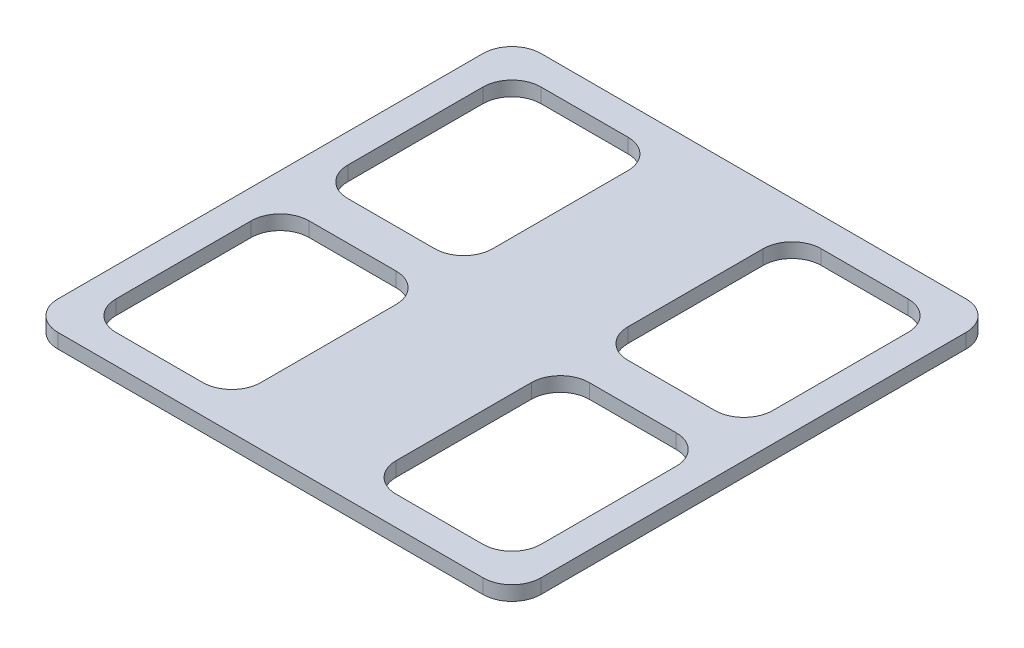
from build123d import *

# Parameters (mm, degrees)
EXTRUDE_1_DEPTH = 15


with BuildPart() as part:
    # 草图1 → 凸台-拉伸1 (new body)
    with BuildSketch(Plane(origin=(0, 0, 0), x_dir=(1, 0, 0), z_dir=(0, 1, 0))):
        with BuildLine():
            Line((220, 250), (-220, 250))
            ThreePointArc((-220, 250), (-241.213203436, 241.213203436), (-250, 220))
            Line((-250, 220), (-250, -220))
            ThreePointArc((-250, -220), (-241.213203436, -241.213203436), (-220, -250))
            Line((-220, -250), (220, -250))
            ThreePointArc((220, -250), (241.213203436, -241.213203436), (250, -220))
            Line((250, -220), (250, 220))
            ThreePointArc((250, 220), (241.213203436, 241.213203436), (220, 250))
        make_face()
        with BuildLine():
            Line((-100, 20), (-190, 20))
            ThreePointArc((-190, 20), (-211.213203436, 28.786796564), (-220, 50))
            Line((-220, 50), (-220, 190))
            ThreePointArc((-220, 190), (-211.213203436, 211.213203436), (-190, 220))
            Line((-190, 220), (-100, 220))
            ThreePointArc((-100, 220), (-78.786796564, 211.213203436), (-70, 190))
            Line((-70, 190), (-70, 50))
            ThreePointArc((-70, 50), (-78.786796564, 28.786796564), (-100, 20))
        make_face(mode=Mode.SUBTRACT)
        with BuildLine():
            Line((220, 50), (220, 190))
            ThreePointArc((220, 190), (211.213203436, 211.213203436), (190, 220))
            Line((190, 220), (100, 220))
            ThreePointArc((100, 220), (78.786796564, 211.213203436), (70, 190))
            Line((70, 190), (70, 50))
            ThreePointArc((70, 50), (78.786796564, 28.786796564), (100, 20))
            Line((100, 20), (190, 20))
            ThreePointArc((190, 20), (211.213203436, 28.786796564), (220, 50))
        make_face(mode=Mode.SUBTRACT)
        with BuildLine():
            Line((-220, -50), (-220, -190))
            ThreePointArc((-220, -190), (-211.213203436, -211.213203436), (-190, -220))
            Line((-190, -220), (-100, -220))
            ThreePointArc((-100, -220), (-78.786796564, -211.213203436), (-70, -190))
            Line((-70, -190), (-70, -50))
            ThreePointArc((-70, -50), (-78.786796564, -28.786796564), (-100, -20))
            Line((-100, -20), (-190, -20))
            ThreePointArc((-190, -20), (-211.213203436, -28.786796564), (-220, -50))
        make_face(mode=Mode.SUBTRACT)
        with BuildLine():
            Line((100, -20), (190, -20))
            ThreePointArc((190, -20), (211.213203436, -28.786796564), (220, -50))
            Line((220, -50), (220, -190))
            ThreePointArc((220, -190), (211.213203436, -211.213203436), (190, -220))
            Line((190, -220), (100, -220))
            ThreePointArc((100, -220), (78.786796564, -211.213203436), (70, -190))
            Line((70, -190), (70, -50))
            ThreePointArc((70, -50), (78.786796564, -28.786796564), (100, -20))
        make_face(mode=Mode.SUBTRACT)
    extrude(amount=EXTRUDE_1_DEPTH)


solid = part.part
